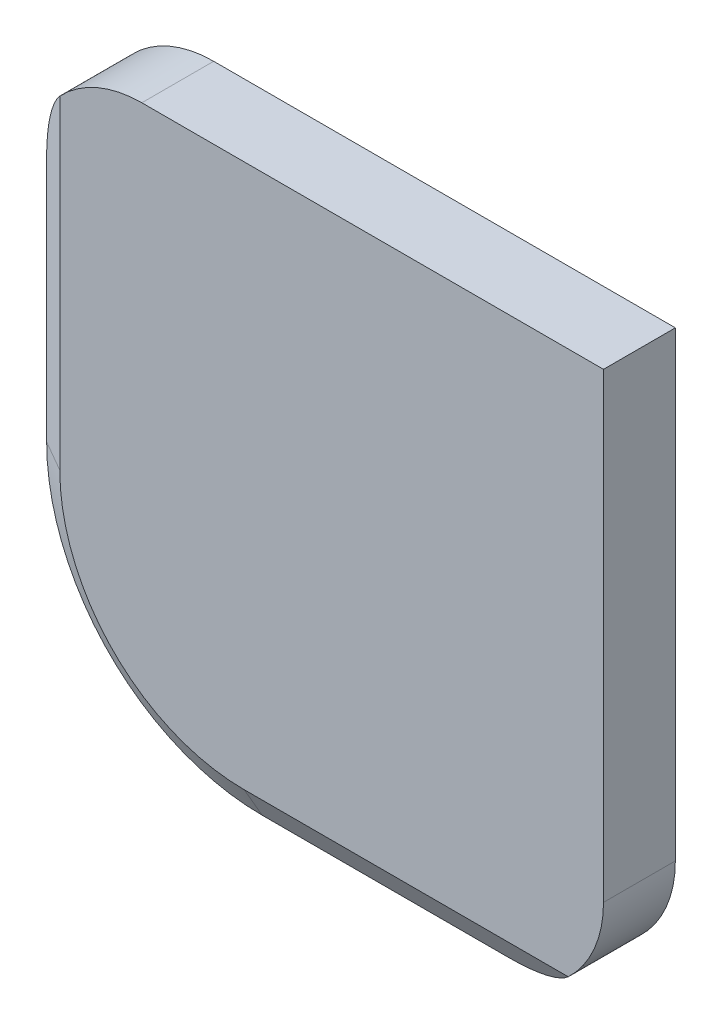
from build123d import *
from OCP.BRepFilletAPI import BRepFilletAPI_MakeChamfer

# Parameters (mm, degrees)
BOSS_EXTRUDE1_DEPTH = 6.35
CHAMFER1_SIZE       = 1.5875
CHAMFER1_SIZE2      = 2.749630657
CHAMFER2_SIZE       = 2.7432
CHAMFER2_SIZE2      = 1.583787258
FILLET1_R           = 10


with BuildPart() as part:
    # Sketch1 → Boss-Extrude1 (new body)
    with BuildSketch(Plane.XY):
        with BuildLine():
            Line((-19.05, 0), (-19.05, 31.75))
            Line((-19.05, 31.75), (31.75, 31.75))
            Line((31.75, 31.75), (31.75, -19.05))
            Line((31.75, -19.05), (0, -19.05))
            ThreePointArc((0, -19.05), (-13.470384182, -13.470384182), (-19.05, 0))
        make_face()
    extrude(amount=BOSS_EXTRUDE1_DEPTH)

    # Chamfer1: one chamfer whose edges measure the first distance from different faces: ONE call of the kernel's chamfer builder (chamfer() names one face for all edges)
    chamfer1_edges_1 = [part.edges().sort_by_distance(p)[0] for p in [
        (-19.05, 15.875, 6.35),
    ]]
    chamfer1_side_1 = [part.faces().sort_by_distance(p)[0] for p in [
        (-19.05, 15.875, 3.175),
    ]]
    chamfer1_edges_2 = [part.edges().sort_by_distance(p)[0] for p in [
        (-13.470384182, -13.470384182, 6.35),
    ]]
    chamfer1_side_2 = [part.faces().sort_by_distance(p)[0] for p in [
        (-13.470384182, -13.470384182, 3.175),
    ]]
    chamfer1_edges_3 = [part.edges().sort_by_distance(p)[0] for p in [
        (15.875, -19.05, 6.35),
    ]]
    chamfer1_side_3 = [part.faces().sort_by_distance(p)[0] for p in [
        (15.875, -19.05, 3.175),
    ]]
    chamfer1 = BRepFilletAPI_MakeChamfer(part.part.solid().wrapped)
    for e in chamfer1_edges_1:
        chamfer1.Add(CHAMFER1_SIZE, CHAMFER1_SIZE2, e.wrapped, chamfer1_side_1[0].wrapped)  # the first distance lies on this face
    for e in chamfer1_edges_2:
        chamfer1.Add(CHAMFER1_SIZE, CHAMFER1_SIZE2, e.wrapped, chamfer1_side_2[0].wrapped)  # the first distance lies on this face
    for e in chamfer1_edges_3:
        chamfer1.Add(CHAMFER1_SIZE, CHAMFER1_SIZE2, e.wrapped, chamfer1_side_3[0].wrapped)  # the first distance lies on this face
    add(Compound.cast(chamfer1.Shape()), mode=Mode.REPLACE)

    # Chamfer2
    chamfer2_edges = [part.edges().sort_by_distance(p)[0] for p in [
        (-19.05, 15.875, 0),
        (15.875, -19.05, 0),
        (-13.470384182, -13.470384182, 0),
    ]]
    chamfer2_side = [part.faces().sort_by_distance(p)[0] for p in [
        (7.007973691, 7.007973691, 0),
    ]]
    chamfer(chamfer2_edges, length=CHAMFER2_SIZE, length2=CHAMFER2_SIZE2, reference=chamfer2_side[0])

    # Fillet1
    fillet1_edges = [part.edges().sort_by_distance(p)[0] for p in [
        (31.75, -19.05, 3.173143629),
        (-19.05, 31.75, 3.173143629),
    ]]
    fillet(fillet1_edges, radius=FILLET1_R)


solid = part.part
